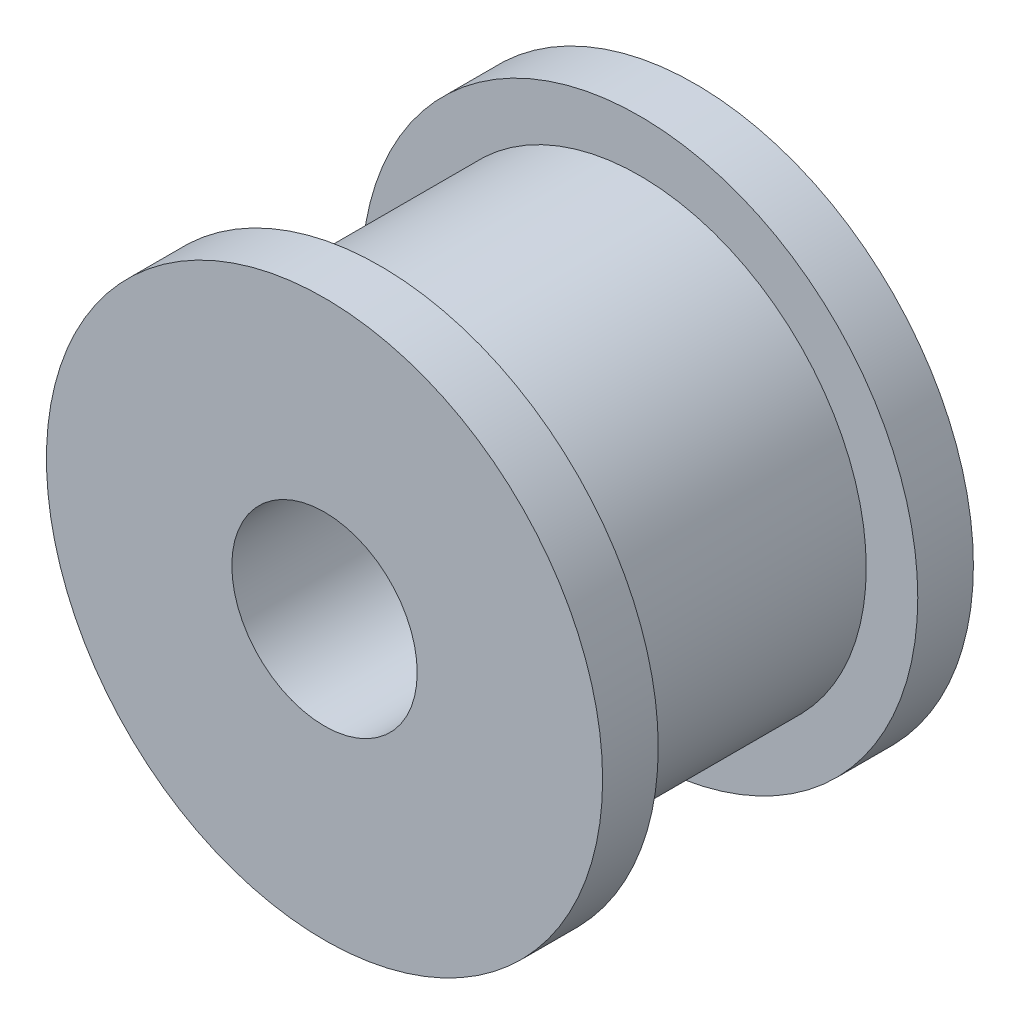
from build123d import *

# Parameters (mm, degrees)
F_5_0MM_DOWEL_HOLE1_D = 5


with BuildPart() as part:
    # Sketch2 → Revolve1 (revolve)
    with BuildSketch(Plane(origin=(0, 0, 0), x_dir=(1, 0, 0), z_dir=(0, 1, 0))):
        Polygon((0, 10), (7.5, 10), (7.5, 8.5), (6.11, 8.5), (6.11, 1.5), (7.5, 1.5), (7.5, 0), (0, 0), align=None)
    revolve(axis=Axis((0, 0, 0), (0, 0, -1)))

    # Ø5.0mm Dowel Hole1 (through all)
    with Locations(Plane(origin=(0, 0, -10), x_dir=(-1, 0, 0), z_dir=(0, 0, -1))):
        with Locations((0, 0)):
            Hole(F_5_0MM_DOWEL_HOLE1_D / 2)


solid = part.part
